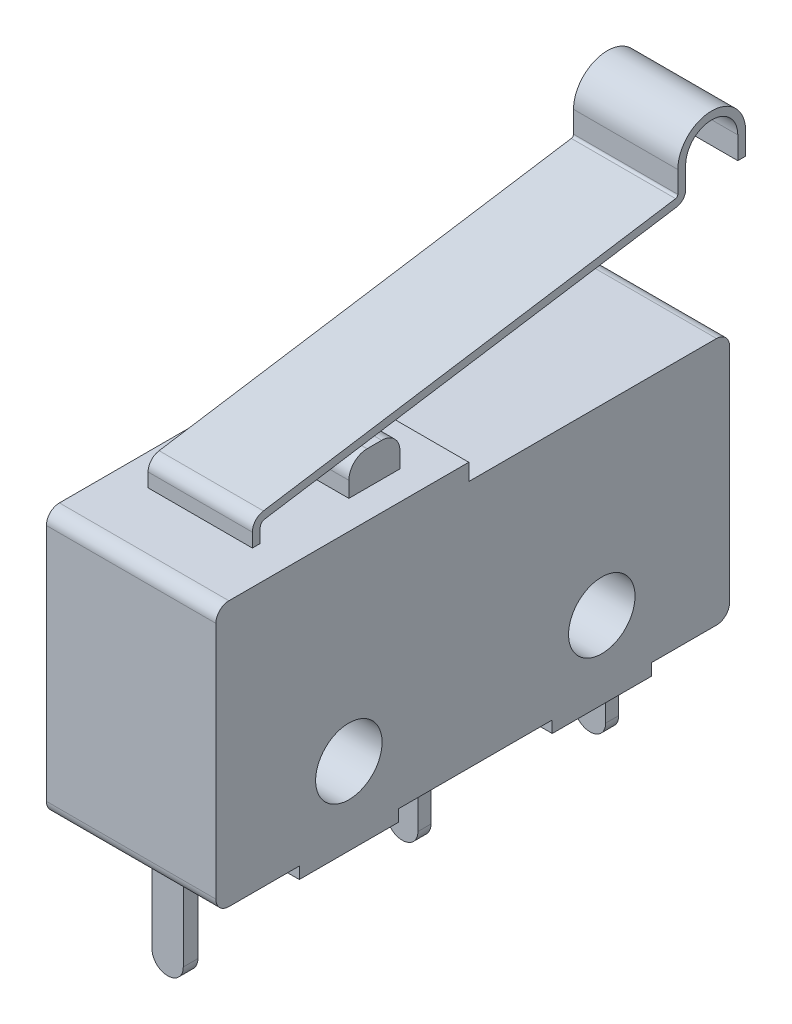
from build123d import *

# Parameters (mm, degrees)
SKETCH1_R               = 1.275
BOSS_EXTRUDE1_DEPTH     = 6.5
SKETCH2_W               = 3.53
SKETCH2_H               = 1.96
BOSS_EXTRUDE2_DEPTH     = 1.3
FILLET1_R               = 0.7
SKETCH3_W               = 3.2
SKETCH3_H               = 0.56
SKETCH3_H_2             = 0.5
BOSS_EXTRUDE3_DEPTH     = 0.9
SKETCH4_W               = 1.2
SKETCH4_H               = 0.56
SKETCH4_H_2             = 0.5
BOSS_EXTRUDE4_DEPTH     = 3.47
FILLET2_R               = 0.59
EXTRU_MINCE1_DEPTH      = 2
EXTRU_MINCE1_DEPTH_BACK = 2


with BuildPart() as part:
    # Sketch1 → Boss-Extrude1 (new body)
    with BuildSketch(Plane(origin=(0, 0, 0), x_dir=(0, 0, -1), z_dir=(1, 0, 0))):
        with BuildLine():
            Line((-9.45, 0), (-6.75, 0))
            Line((-6.75, 0), (-6.75, -0.45))
            Line((-6.75, -0.45), (-2.95, -0.45))
            Line((-2.95, -0.45), (-2.95, 0))
            Line((-2.95, 0), (2.95, 0))
            Line((2.95, 0), (2.95, -0.45))
            Line((2.95, -0.45), (6.75, -0.45))
            Line((6.75, -0.45), (6.75, 0))
            Line((6.75, 0), (9.25, 0))
            ThreePointArc((9.25, 0), (9.603553391, 0.146446609), (9.75, 0.5))
            Line((9.75, 0.5), (9.75, 9.02))
            ThreePointArc((9.75, 9.02), (9.603553391, 9.373553391), (9.25, 9.52))
            Line((9.25, 9.52), (-0.25, 9.52))
            Line((-0.25, 9.52), (-0.25, 10.16))
            Line((-0.25, 10.16), (-9.45, 10.16))
            ThreePointArc((-9.45, 10.16), (-9.803553391, 10.013553391), (-9.95, 9.66))
            Line((-9.95, 9.66), (-9.95, 0.5))
            ThreePointArc((-9.95, 0.5), (-9.803553391, 0.146446609), (-9.45, 0))
        make_face()
        with Locations((-4.85, 2.525)):
            Circle(SKETCH1_R, mode=Mode.SUBTRACT)
        with Locations((4.85, 2.525)):
            Circle(SKETCH1_R, mode=Mode.SUBTRACT)
    extrude(amount=BOSS_EXTRUDE1_DEPTH)

    # Sketch2 → Boss-Extrude2 (add)
    with BuildSketch(Plane(origin=(0, 10.16, 0), x_dir=(1, 0, 0), z_dir=(0, 1, 0))):
        with Locations((3.635, -2.77)):
            Rectangle(SKETCH2_W, SKETCH2_H)
    extrude(amount=BOSS_EXTRUDE2_DEPTH)

    # Fillet1
    fillet1_edges = [part.edges().sort_by_distance(p)[0] for p in [
        (3.635, 11.46, 3.75),
        (3.635, 11.46, 1.79),
    ]]
    fillet(fillet1_edges, radius=FILLET1_R)

    # Sketch3 → Boss-Extrude3 (add)
    with BuildSketch(Plane(origin=(0, 0, 0), x_dir=(-1, 0, 0), z_dir=(0, -1, 0))):
        with Locations((-3.25, -8.27)):
            Rectangle(SKETCH3_W, SKETCH3_H)
        with Locations((-3.25, 0.7)):
            Rectangle(SKETCH3_W, SKETCH3_H_2)
        with Locations((-3.25, 7.9)):
            Rectangle(SKETCH3_W, SKETCH3_H_2)
    extrude(amount=BOSS_EXTRUDE3_DEPTH)

    # Sketch4 → Boss-Extrude4 (add)
    with BuildSketch(Plane(origin=(0, -0.9, 0), x_dir=(-1, 0, 0), z_dir=(0, -1, 0))):
        with Locations((-3.25, -8.27)):
            Rectangle(SKETCH4_W, SKETCH4_H)
        with Locations((-3.25, 0.7)):
            Rectangle(SKETCH4_W, SKETCH4_H_2)
        with Locations((-3.25, 7.9)):
            Rectangle(SKETCH4_W, SKETCH4_H_2)
    extrude(amount=BOSS_EXTRUDE4_DEPTH)

    # Fillet2
    fillet2_edges = [part.edges().sort_by_distance(p)[0] for p in [
        (2.65, -4.37, 8.27),
        (3.85, -4.37, 8.27),
        (2.65, -4.37, -0.7),
        (3.85, -4.37, -0.7),
        (3.85, -4.37, -7.9),
        (2.65, -4.37, -7.9),
    ]]
    fillet(fillet2_edges, radius=FILLET2_R)

    # Esquisse1 → Extru.-Mince1 (add, two sides)
    with BuildSketch(Plane(origin=(3.2, 0, 0), x_dir=(0, 0, -1), z_dir=(1, 0, 0))) as extru_mince1_sk:
        with BuildLine():
            Line((-7.25, 10.16), (-7.25, 10.688783991))
            ThreePointArc((-7.25, 10.688783991), (-7.129827698, 11.013946904), (-6.82707632, 11.182807513))
            Line((-6.82707632, 11.182807513), (8.981676404, 13.649249751))
            ThreePointArc((8.981676404, 13.649249751), (9.04222668, 13.683021873), (9.06626114, 13.748054456))
            Line((9.06626114, 13.748054456), (9.06626114, 14.573737504))
            ThreePointArc((9.06626114, 14.573737504), (10.36626114, 15.873737504), (11.66626114, 14.573737504))
            Line((11.66626114, 14.573737504), (11.66626114, 13.717657457))
            Line((11.66626114, 13.717657457), (11.36616114, 13.717657457))
            Line((11.36616114, 13.717657457), (11.36616114, 14.573737504))
            ThreePointArc((11.36616114, 14.573737504), (10.36626114, 15.573637504), (9.36636114, 14.573737504))
            Line((9.36636114, 14.573737504), (9.36636114, 13.748054456))
            ThreePointArc((9.36636114, 13.748054456), (9.270199264, 13.487859093), (9.027937611, 13.352736833))
            Line((9.027937611, 13.352736833), (-6.780815113, 10.886294595))
            ThreePointArc((-6.780815113, 10.886294595), (-6.901855114, 10.818784123), (-6.9499, 10.688783991))
            Line((-6.9499, 10.688783991), (-6.9499, 10.16))
            Line((-6.9499, 10.16), (-7.25, 10.16))
        make_face()
    extrude(amount=EXTRU_MINCE1_DEPTH)
    extrude(extru_mince1_sk.sketch, amount=-EXTRU_MINCE1_DEPTH_BACK)


solid = part.part
